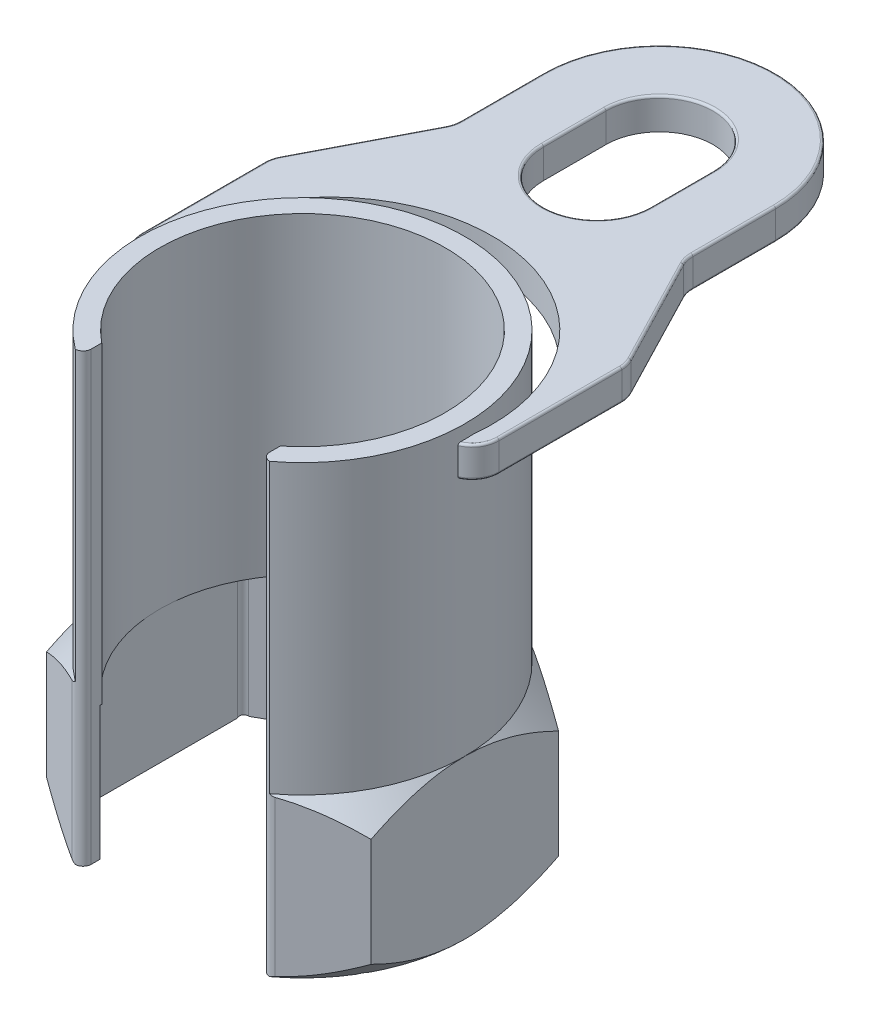
from build123d import *
from build123d.topology import SkipClean

# Parameters (mm, degrees)
EXTRUDE1_DEPTH     = 35.5
EXTRUDE2_DEPTH     = 64.5
SKETCH8_OUTSIDE_W  = 305.41
SKETCH8_OUTSIDE_H  = 305.117
SKETCH8_OUTSIDE_R  = 36.373066959
CUT_EXTRUDE4_DEPTH = 101
CUT_EXTRUDE4_DRAFT = -45
SKETCH19_OUTSIDE_W = 176.41
SKETCH19_OUTSIDE_H = 176.117
SKETCH19_OUTSIDE_R = 36.372966959
CUT_EXTRUDE6_DEPTH = 36.5
CUT_EXTRUDE6_DRAFT = -45
CUT_EXTRUDE9_START = -29.872967
CUT_EXTRUDE9_DEPTH = 29.872975
FILLET1_R          = 1.8
EXTRUDE7_DEPTH     = 7
CUT_EXTRUDE8_REACH = 99
FILLET4_R          = 0.5


with BuildPart() as part:
    # Sketch1 → Extrude1 (new body)
    with BuildSketch(Plane(origin=(0, 0, 0), x_dir=(1, 0, 0), z_dir=(0, 1, 0))):
        with BuildLine():
            Line((-20, -24.979991994), (-20, -30.452994616))
            Line((-20, -30.452994616), (-36.373066959, -21))
            Line((-36.373066959, -21), (-36.373066959, 21))
            Line((-36.373066959, 21), (0, 42))
            Line((0, 42), (36.373066959, 21))
            Line((36.373066959, 21), (36.373066959, -21))
            Line((36.373066959, -21), (20, -30.452994616))
            Line((20, -30.452994616), (20, -24.979991994))
            ThreePointArc((20, -24.979991994), (0, 32), (-20, -24.979991994))
        make_face()
    extrude(amount=EXTRUDE1_DEPTH)

    # Sketch3 → Extrude2 (add)
    with BuildSketch(Plane(origin=(0, 35.5, 0), x_dir=(-1, 0, 0), z_dir=(0, 1, 0))):
        with BuildLine():
            Line((-20, 30.380795338), (-20, 24.979991994))
            ThreePointArc((-20, 24.979991994), (0, -32), (20, 24.979991994))
            Line((20, 24.979991994), (20, 30.380795338))
            ThreePointArc((20, 30.380795338), (0, -36.372966959), (-20, 30.380795338))
        make_face()
    extrude(amount=EXTRUDE2_DEPTH)


with BuildPart() as cut_extrude4_tool:
    # Sketch8 outside → Cut-Extrude4 (with draft: the straight prism first)
    with BuildSketch(Plane.XZ):
        with Locations((0, -5.7735)):
            Rectangle(SKETCH8_OUTSIDE_W, SKETCH8_OUTSIDE_H)
        Circle(SKETCH8_OUTSIDE_R, mode=Mode.SUBTRACT)
    extrude(amount=-CUT_EXTRUDE4_DEPTH)
    # Cut-Extrude4: the draft: its side faces are tilted about the plane it starts from
    cut_extrude4_sides = [cut_extrude4_tool.faces().sort_by_distance(p)[0] for p in [
        (0, 50.5, -158.332),
        (152.705, 50.5, -5.7735),
        (0, 50.5, 146.785),
        (-152.705, 50.5, -5.7735),
        (-36.373066959, 50.5, 0),
    ]]
    draft(cut_extrude4_sides, Plane.XZ, CUT_EXTRUDE4_DRAFT)


with BuildPart() as part_1:
    add(part.part)

    # Cut-Extrude4: cut by cut_extrude4_tool
    add(cut_extrude4_tool.part, mode=Mode.SUBTRACT)


with BuildPart() as cut_extrude6_tool:
    # Sketch19 outside → Cut-Extrude6 (with draft: the straight prism first)
    with BuildSketch(Plane(origin=(0, 35.5, 0), x_dir=(-1, 0, 0), z_dir=(0, 1, 0))):
        with Locations((0, -5.7735)):
            Rectangle(SKETCH19_OUTSIDE_W, SKETCH19_OUTSIDE_H)
        Circle(SKETCH19_OUTSIDE_R, mode=Mode.SUBTRACT)
    extrude(amount=-CUT_EXTRUDE6_DEPTH)
    # Cut-Extrude6: the draft: its side faces are tilted about the plane it starts from
    cut_extrude6_sides = [cut_extrude6_tool.faces().sort_by_distance(p)[0] for p in [
        (0, 17.25, -93.832),
        (-88.205, 17.25, -5.7735),
        (0, 17.25, 82.285),
        (88.205, 17.25, -5.7735),
        (36.372966959, 17.25, 0),
    ]]
    draft(cut_extrude6_sides, Plane(origin=(0, 35.5, 0), x_dir=(-1, 0, 0), z_dir=(0, 1, 0)), CUT_EXTRUDE6_DRAFT)


with BuildPart() as part_2:
    add(part_1.part)

    # Cut-Extrude6: cut by cut_extrude6_tool
    add(cut_extrude6_tool.part, mode=Mode.SUBTRACT)

    # Sketch26 → Cut-Extrude9 (cut)
    with BuildSketch(Plane.XZ.offset(CUT_EXTRUDE9_START)):
        Polygon((-32, -18.475208614), (0, -36.950417228), (32, -18.475208614), (32, 18.475208614), (0, 36.950417228), (-32, 18.475208614), align=None)
    extrude(amount=CUT_EXTRUDE9_DEPTH, mode=Mode.SUBTRACT)

    # Fillet1
    fillet1_edges = [part_2.edges().sort_by_distance(p)[0] for p in [
        (-32, 15.225158635, -18.475208614),
        (-32, 15.225158635, 18.475208614),
        (32, 15.225158635, 18.475208614),
        (32, 15.225158635, -18.475208614),
        (-20, 17.74995, 30.452994616),
        (20, 17.74995, 30.452994616),
        (0, 15.225158635, -36.950417228),
    ]]
    fillet(fillet1_edges, radius=FILLET1_R)

    # Sketch16 → Extrude7 (add)
    with BuildSketch(Plane(origin=(0, 90, 0), x_dir=(-1, 0, 0), z_dir=(0, 1, 0))):
        with BuildLine():
            Line((-26, -80), (-26, -61.463062565))
            ThreePointArc((-26, -61.463062565), (-26.170799234, -60.041648328), (-26.673472811, -58.701159578))
            Line((-26.673472811, -58.701159578), (-39.326527189, -34.298840422))
            ThreePointArc((-39.326527189, -34.298840422), (-39.829200766, -32.958351672), (-40, -31.536937435))
            Line((-40, -31.536937435), (-40, -4.024031362))
            ThreePointArc((-40, -4.024031362), (-39.002606591, -0.711339511), (-36.342024234, 1.5))
            ThreePointArc((-36.342024234, 1.5), (0, -36.372966959), (36.342024234, 1.5))
            ThreePointArc((36.342024234, 1.5), (39.002606591, -0.711339511), (40, -4.024031362))
            Line((40, -4.024031362), (40, -31.536937435))
            ThreePointArc((40, -31.536937435), (39.829200766, -32.958351672), (39.326527189, -34.298840422))
            Line((39.326527189, -34.298840422), (26.673472811, -58.701159578))
            ThreePointArc((26.673472811, -58.701159578), (26.170799234, -60.041648328), (26, -61.463062565))
            Line((26, -61.463062565), (26, -80))
            ThreePointArc((26, -80), (0, -106), (-26, -80))
        make_face()
    extrude(amount=EXTRUDE7_DEPTH)

    # Sketch25 → Cut-Extrude8 (cut, up to next)
    with BuildSketch(Plane.XZ.offset(-97), mode=Mode.PRIVATE) as cut_extrude8_sk1:
        with BuildLine():
            Line((-12, -80), (-12, -66))
            ThreePointArc((-12, -66), (0, -54), (12, -66))
            Line((12, -66), (12, -80))
            ThreePointArc((12, -80), (0, -92), (-12, -80))
        make_face()
    cut_extrude8_tool1 = extrude(cut_extrude8_sk1.sketch, amount=CUT_EXTRUDE8_REACH, mode=Mode.PRIVATE) & part_2.part
    add(cut_extrude8_tool1.solids().sort_by_distance((0, 97, -73))[0], mode=Mode.SUBTRACT)
    # Sketch25 → Cut-Extrude8 (cut, up to next)
    with BuildSketch(Plane.XZ.offset(-97), mode=Mode.PRIVATE) as cut_extrude8_sk2:
        with BuildLine():
            ThreePointArc((36.317939443, -2), (0, -36.372966959), (-36.317939443, -2))
            ThreePointArc((-36.317939443, -2), (0, -42.537552263), (36.317939443, -2))
        make_face()
    cut_extrude8_tool2 = extrude(cut_extrude8_sk2.sketch, amount=CUT_EXTRUDE8_REACH, mode=Mode.PRIVATE) & part_2.part
    add(cut_extrude8_tool2.solids().sort_by_distance((0, 97, -41.701893))[0], mode=Mode.SUBTRACT)

    # Fillet4
    fillet4_edges = [part_2.edges().sort_by_distance(p)[0] for p in [
        (-39.002606591, 90, -0.711339511),
        (39.002606591, 90, -0.711339511),
        (40, 90, -17.780484399),
        (39.829200766, 90, -32.958351672),
        (33, 90, -46.5),
        (26.170799234, 90, -60.041648328),
        (26, 90, -70.731531282),
        (0, 90, -106),
        (-26, 90, -70.731531282),
        (-26.170799234, 90, -60.041648328),
        (-33, 90, -46.5),
        (-39.829200766, 90, -32.958351672),
        (-40, 90, -17.780484399),
        (-39.002606591, 97, -0.711339511),
        (39.002606591, 97, -0.711339511),
        (40, 97, -17.780484399),
        (39.829200766, 97, -32.958351672),
        (33, 97, -46.5),
        (26.170799234, 97, -60.041648328),
        (26, 97, -70.731531282),
        (0, 97, -106),
        (-26, 97, -70.731531282),
        (-26.170799234, 97, -60.041648328),
        (-33, 97, -46.5),
        (-39.829200766, 97, -32.958351672),
        (-40, 97, -17.780484399),
        (0, 97, -92),
        (12, 97, -73),
        (0, 97, -54),
        (-12, 97, -73),
    ]]
    fillet(fillet4_edges, radius=FILLET4_R)


solid = part_2.part
